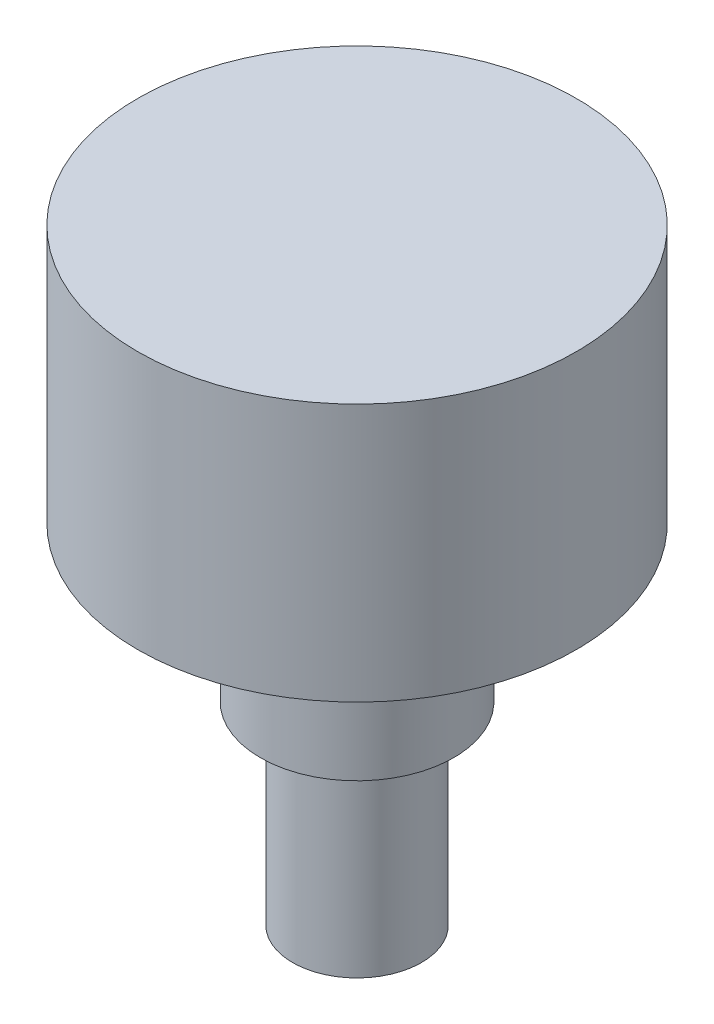
from build123d import *

# Parameters (mm, degrees)
SKETCH1_R           = 10.795
BOSS_EXTRUDE1_DEPTH = 12.7
SKETCH2_R           = 4.7625
BOSS_EXTRUDE2_DEPTH = 17.145
SKETCH3_OUTSIDE_W   = 32.13
SKETCH3_OUTSIDE_H   = 32.13
SKETCH3_OUTSIDE_R   = 3.175
CUT_EXTRUDE1_DEPTH  = 9.525


with BuildPart() as part:
    # Sketch1 → Boss-Extrude1 (new body)
    with BuildSketch(Plane(origin=(0, 0, 0), x_dir=(1, 0, 0), z_dir=(0, 1, 0))):
        Circle(SKETCH1_R)
    extrude(amount=BOSS_EXTRUDE1_DEPTH)

    # Sketch2 → Boss-Extrude2 (add)
    with BuildSketch(Plane.XZ):
        Circle(SKETCH2_R)
    extrude(amount=BOSS_EXTRUDE2_DEPTH)

    # Sketch3 outside → Cut-Extrude1 (cut)
    with BuildSketch(Plane.XZ.offset(17.145)):
        Rectangle(SKETCH3_OUTSIDE_W, SKETCH3_OUTSIDE_H)
        Circle(SKETCH3_OUTSIDE_R, mode=Mode.SUBTRACT)
    extrude(amount=-CUT_EXTRUDE1_DEPTH, mode=Mode.SUBTRACT)


solid = part.part
